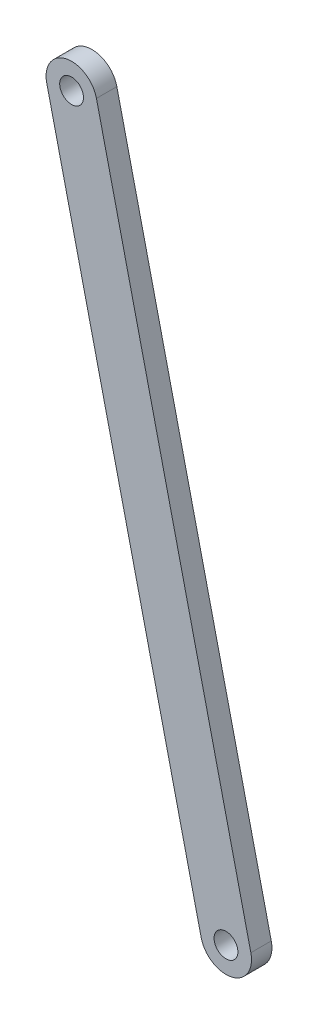
from build123d import *

# Parameters (mm, degrees)
SKETCH1_R           = 3.5
BOSS_EXTRUDE1_DEPTH = 6


with BuildPart() as part:
    # Sketch1 → Boss-Extrude1 (new body)
    with BuildSketch(Plane.XY):
        with BuildLine():
            Line((-38.078175548, -51.593794107), (7.304363278, -246.37681485))
            ThreePointArc((7.304363278, -246.37681485), (1.701845206, -255.383023334), (-7.304363278, -249.780505262))
            Line((-7.304363278, -249.780505262), (-52.686902103, -54.997484519))
            ThreePointArc((-52.686902103, -54.997484519), (-47.084384031, -45.991276035), (-38.078175548, -51.593794107))
        make_face()
        with Locations((-45.382538826, -53.295639313)):
            Circle(SKETCH1_R, mode=Mode.SUBTRACT)
        with Locations((0, -248.078660056)):
            Circle(SKETCH1_R, mode=Mode.SUBTRACT)
    extrude(amount=BOSS_EXTRUDE1_DEPTH)


solid = part.part
